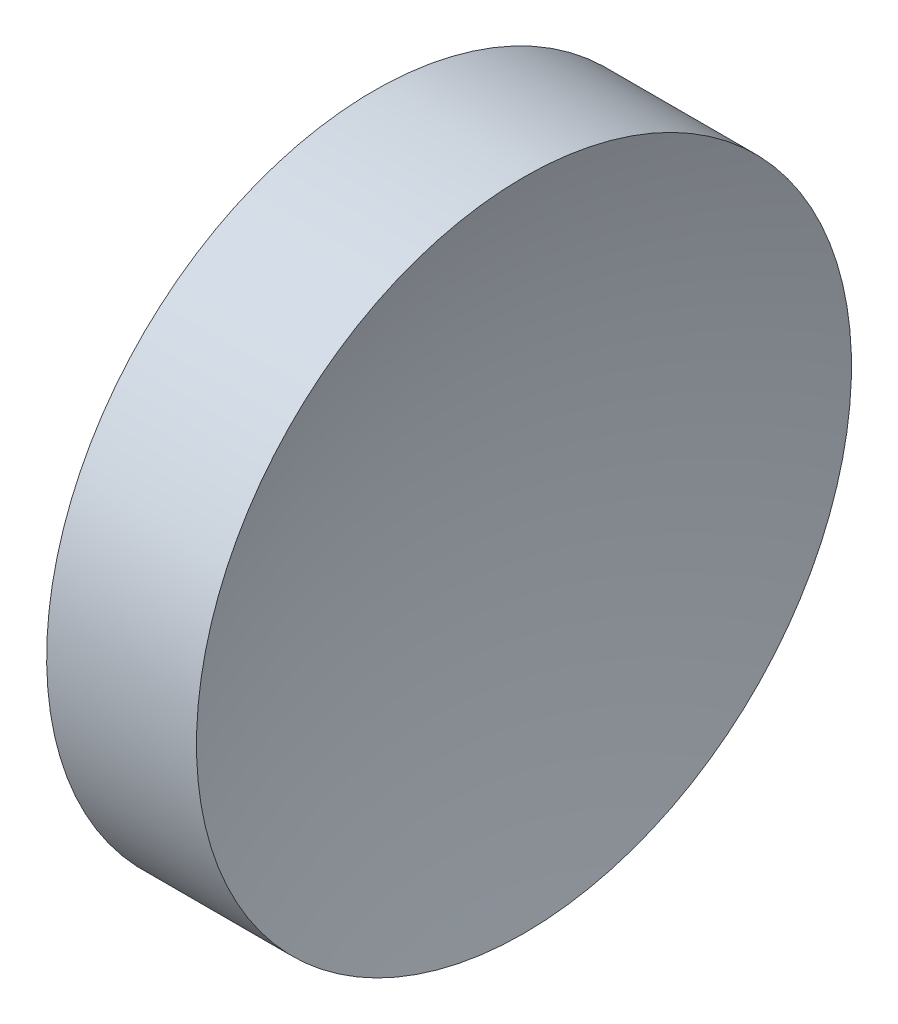
from build123d import *


with BuildPart() as part:
    # 草图1 → 旋转1 (revolve)
    with BuildSketch(Plane.XY):
        with BuildLine():
            Line((22.424232054, 13.031126091), (22.424232054, 18.031126091))
            Line((22.424232054, 18.031126091), (24.711567554, 18.031126091))
            ThreePointArc((24.711567554, 18.031126091), (24.122271199, 15.56193116), (23.924232054, 13.031126091))
            Line((23.924232054, 13.031126091), (22.424232054, 13.031126091))
        make_face()
    revolve(axis=Axis((21.505975118, 13.031126091, 0), (1, 0, 0)))


solid = part.part
